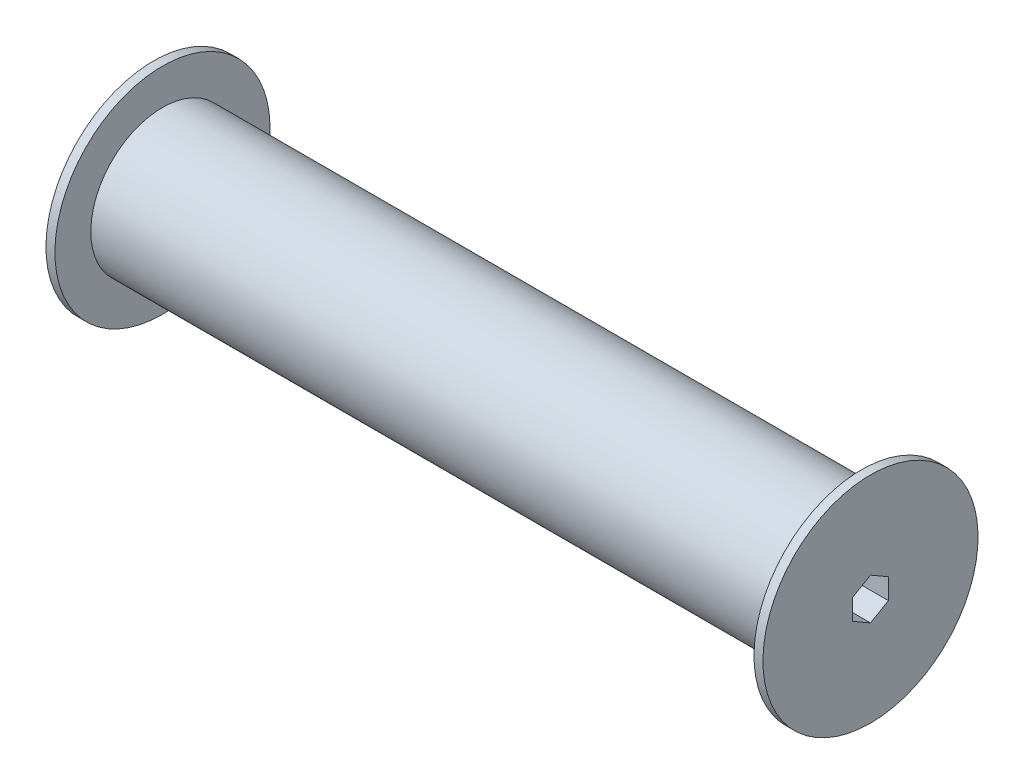
from build123d import *

# Parameters (mm, degrees)
CUT_EXTRUDE1_DEPTH = 255


with BuildPart() as part:
    # Sketch1 → Revolve1 (revolve)
    with BuildSketch(Plane.XY):
        Polygon((-127, 38.1), (-127, 0), (127, 0), (127, 38.1), (123.825, 38.1), (123.825, 25.4), (-123.825, 25.4), (-123.825, 38.1), align=None)
    revolve(axis=Axis((-127, 0, 0), (1, 0, 0)))

    # Sketch2 → Cut-Extrude1 (cut, through all)
    with BuildSketch(Plane(origin=(127, 0, 0), x_dir=(0, 0, -1), z_dir=(1, 0, 0))):
        Polygon((0, 7.332348419), (-6.35, 3.666174209), (-6.35, -3.666174209), (0, -7.332348419), (6.35, -3.666174209), (6.35, 3.666174209), align=None)
    extrude(amount=-CUT_EXTRUDE1_DEPTH, mode=Mode.SUBTRACT)


solid = part.part
